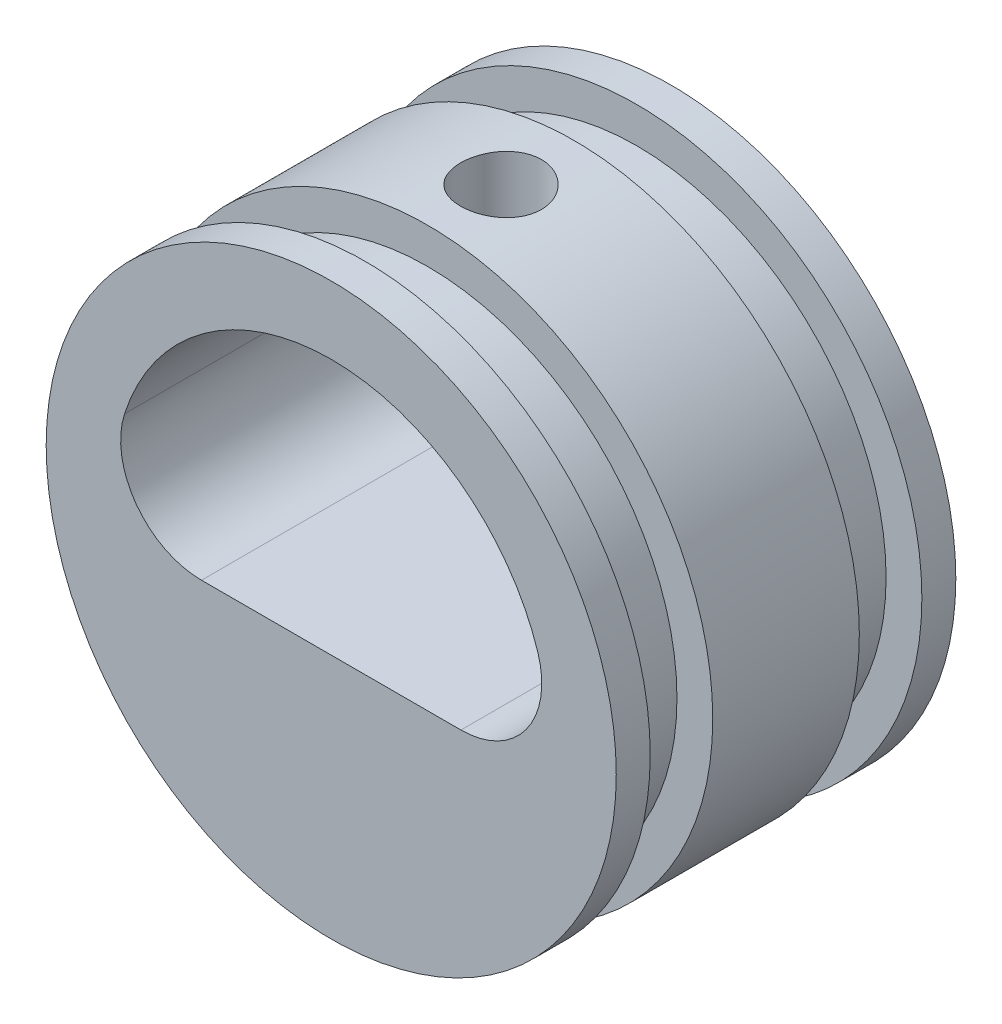
from build123d import *

# Parameters (mm, degrees)
SKETCH1_R                          = 16.7894
BOSS_EXTRUDE1_DEPTH                = 20
SKETCH2_W                          = 3.683
SKETCH2_H                          = 2.1082
CUT_EXTRUDE1_DEPTH                 = 21
FILLET1_R                          = 4.7625
F_3_16_0_1875_DIAMETER_HOLE1_D     = 4.7625
F_3_16_0_1875_DIAMETER_HOLE1_DEPTH = 11.543700016
F_3_16_0_1875_DIAMETER_HOLE1_TIP   = 1.430799349


with BuildPart() as part:
    # Sketch1 → Boss-Extrude1 (new body)
    with BuildSketch(Plane.XY):
        Circle(SKETCH1_R)
    extrude(amount=BOSS_EXTRUDE1_DEPTH)

    # Sketch2 → Cut-Revolve1 (revolve, cut)
    with BuildSketch(Plane(origin=(0, 0, 0), x_dir=(0, 0, -1), z_dir=(1, 0, 0))):
        with Locations((-16.1585, 15.7353)):
            Rectangle(SKETCH2_W, SKETCH2_H)
        with Locations((-3.8415, 15.7353)):
            Rectangle(SKETCH2_W, SKETCH2_H)
    revolve(axis=Axis((0, 0, 21.240749408), (0, 0, -1)), mode=Mode.SUBTRACT)

    # Sketch3 → Cut-Extrude1 (cut, through all)
    with BuildSketch(Plane.XY.offset(20)):
        with BuildLine():
            Line((-12.580888371, -2.300000032), (12.580888371, -2.300000032))
            ThreePointArc((12.580888371, -2.300000032), (0, 12.7894), (-12.580888371, -2.300000032))
        make_face()
    extrude(amount=-CUT_EXTRUDE1_DEPTH, mode=Mode.SUBTRACT)

    # Fillet1
    fillet1_edges = [part.edges().sort_by_distance(p)[0] for p in [
        (-12.580888371, -2.300000032, 10),
        (12.580888371, -2.300000032, 10),
    ]]
    fillet(fillet1_edges, radius=FILLET1_R)

    # 3/16 (0.1875) Diameter Hole1
    with Locations(Plane(origin=(0, 16.7894, 0), x_dir=(-1, 0, 0), z_dir=(0, 1, 0))):
        with Locations((0, 10)):
            Hole(F_3_16_0_1875_DIAMETER_HOLE1_D / 2, depth=F_3_16_0_1875_DIAMETER_HOLE1_DEPTH)
            with Locations((0, 0, -(F_3_16_0_1875_DIAMETER_HOLE1_DEPTH + F_3_16_0_1875_DIAMETER_HOLE1_TIP / 2))):  # 118° drill point
                Cone(0, F_3_16_0_1875_DIAMETER_HOLE1_D / 2, F_3_16_0_1875_DIAMETER_HOLE1_TIP, mode=Mode.SUBTRACT)


solid = part.part
